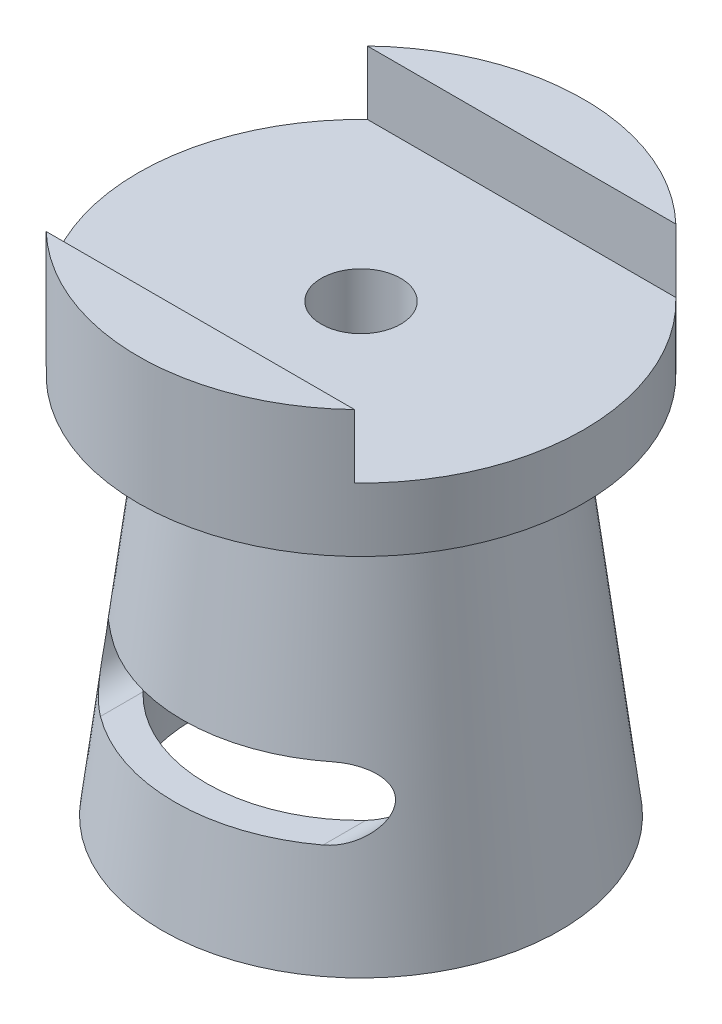
from build123d import *

# Parameters (mm, degrees)
SKETCH3_R           = 7
BOSS_EXTRUDE1_DEPTH = 4
CUT_EXTRUDE1_DEPTH  = 2
SKETCH7_R           = 1.25
CUT_EXTRUDE2_DEPTH  = 3
CUT_EXTRUDE3_DEPTH  = 10


with BuildPart() as part:
    # Sketch1 → Revolve1 (revolve)
    with BuildSketch(Plane.XY):
        Polygon((0, 10), (3.9, 10), (5.127845609, 0), (5.25063017, -1), (6.258139995, -1), (4.784725265, 11), (0, 11), align=None)
    revolve(axis=Axis((0, 10, 0), (0, 1, 0)))

    # Sketch3 → Boss-Extrude1 (add)
    with BuildSketch(Plane(origin=(0, 11, 0), x_dir=(1, 0, 0), z_dir=(0, 1, 0))):
        Circle(SKETCH3_R)
    extrude(amount=BOSS_EXTRUDE1_DEPTH)

    # Sketch5 → Cut-Extrude1 (cut)
    with BuildSketch(Plane(origin=(0, 15, 0), x_dir=(1, 0, 0), z_dir=(0, 1, 0))):
        with BuildLine():
            Line((-4.847421995, 5.05), (4.847421995, 5.05))
            ThreePointArc((4.847421995, 5.05), (7, 0), (4.847421995, -5.05))
            Line((4.847421995, -5.05), (-4.847421995, -5.05))
            ThreePointArc((-4.847421995, -5.05), (-7, 0), (-4.847421995, 5.05))
        make_face()
    extrude(amount=-CUT_EXTRUDE1_DEPTH, mode=Mode.SUBTRACT)

    # Sketch7 → Cut-Extrude2 (cut)
    with BuildSketch(Plane(origin=(0, 13, 0), x_dir=(1, 0, 0), z_dir=(0, 1, 0))):
        Circle(SKETCH7_R)
    extrude(amount=-CUT_EXTRUDE2_DEPTH, mode=Mode.SUBTRACT)

    # Sketch8 → Cut-Extrude3 (cut)
    with BuildSketch(Plane.XY):
        with BuildLine():
            Line((-3.5, 4.392195616), (3.5, 4.392195616))
            ThreePointArc((3.5, 4.392195616), (4.55, 3.342195616), (3.5, 2.292195616))
            Line((3.5, 2.292195616), (-3.5, 2.292195616))
            ThreePointArc((-3.5, 2.292195616), (-4.55, 3.342195616), (-3.5, 4.392195616))
        make_face()
    extrude(amount=CUT_EXTRUDE3_DEPTH, mode=Mode.SUBTRACT)


solid = part.part
